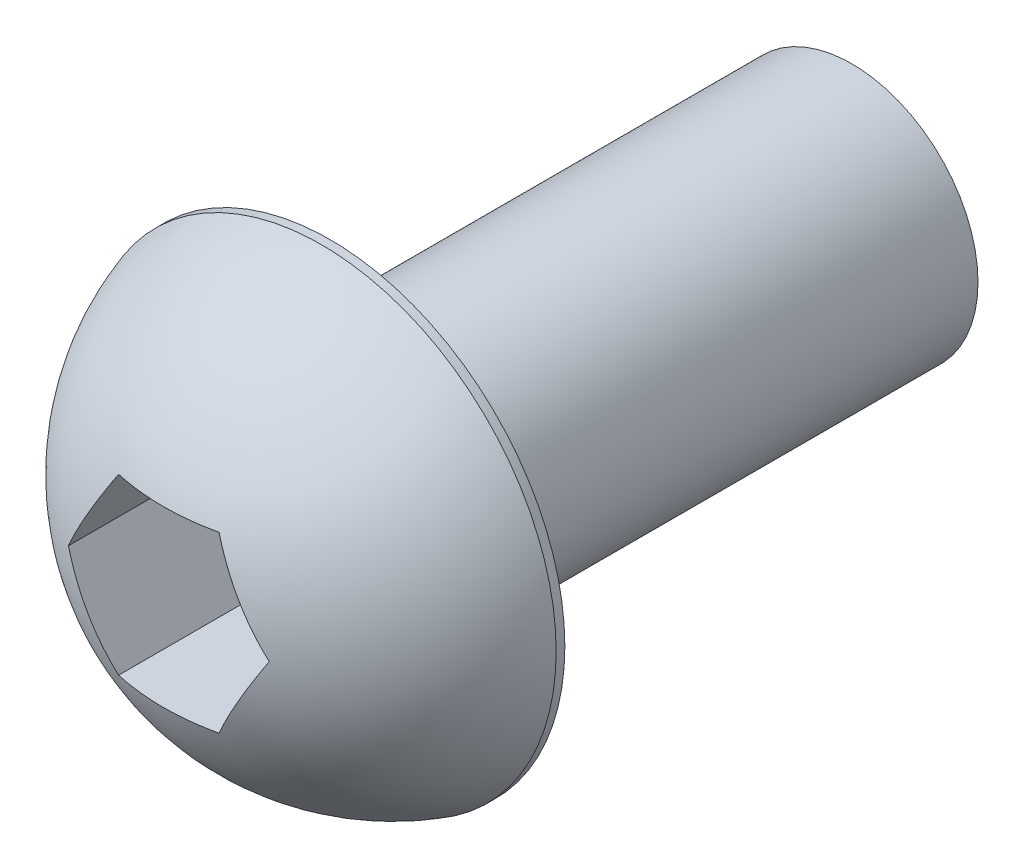
from build123d import *

# Parameters (mm, degrees)
SKETCH1_R           = 1.45
BOSS_EXTRUDE1_DEPTH = 6
SKETCH2_R           = 2.7
BOSS_EXTRUDE2_DEPTH = 0.1
DOME1_FACE_RADIUS   = 2.7
DOME1_HEIGHT        = 2
CUT_EXTRUDE1_DEPTH  = 3.1


with BuildPart() as part:
    # Sketch1 → Boss-Extrude1 (new body)
    with BuildSketch(Plane.XY):
        Circle(SKETCH1_R)
    extrude(amount=BOSS_EXTRUDE1_DEPTH)

    # Sketch2 → Boss-Extrude2 (add)
    with BuildSketch(Plane.XY.offset(6)):
        Circle(SKETCH2_R)
    extrude(amount=BOSS_EXTRUDE2_DEPTH)

    # Dome1: a dome of height H over a round flat face of radius A is a cap of a sphere of radius (A * A + H * H) / (2 * H)
    dome1_r = (DOME1_FACE_RADIUS * DOME1_FACE_RADIUS + DOME1_HEIGHT * DOME1_HEIGHT) / (2 * DOME1_HEIGHT)
    dome1_base = Plane((0, 0, 6.1), z_dir=(0, 0, 1))
    with Locations(dome1_base.offset(DOME1_HEIGHT - dome1_r)):
        dome1_ball = Sphere(dome1_r, mode=Mode.PRIVATE)
    add(split(dome1_ball, bisect_by=dome1_base, keep=Keep.TOP, mode=Mode.PRIVATE))

    # Sketch3 → Cut-Extrude1 (cut, through all)
    with BuildSketch(Plane(origin=(0, 0, 6), x_dir=(-1, 0, 0), z_dir=(0, 0, -1))):
        Polygon((-0.577350269, 1), (-1.154700538, 0), (-0.577350269, -1), (0.577350269, -1), (1.154700538, 0), (0.577350269, 1), align=None)
    extrude(amount=-CUT_EXTRUDE1_DEPTH, mode=Mode.SUBTRACT)


solid = part.part
